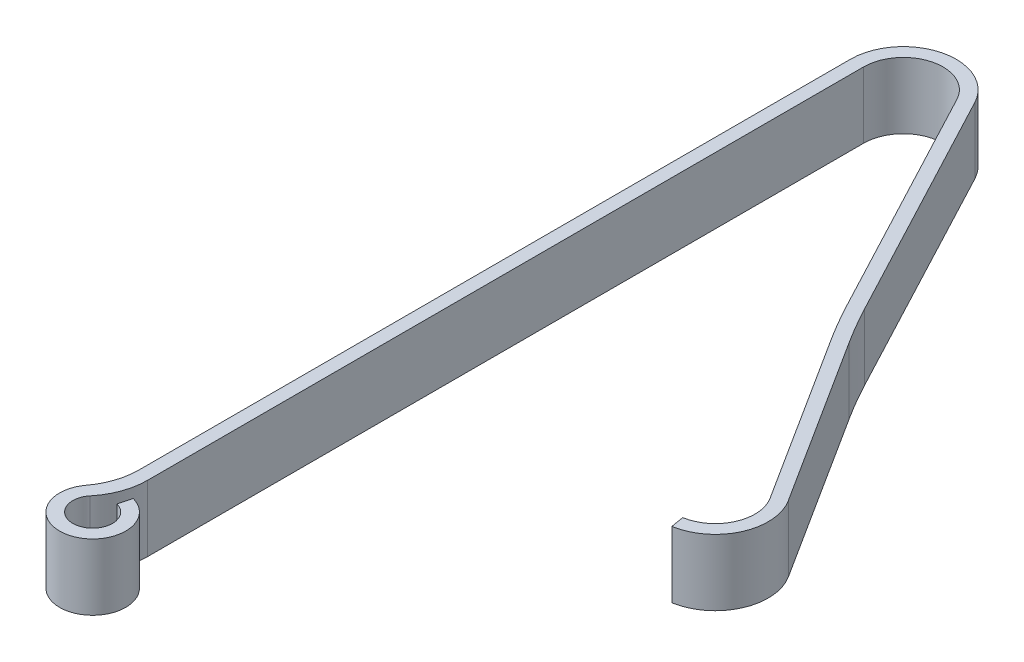
from build123d import *

# Parameters (mm, degrees)
BOSS_EXTRUDE1_DEPTH = 1.27
FILLET1_R           = 1.27


with BuildPart() as part:
    # Sketch1 → Boss-Extrude1 (new body)
    with BuildSketch(Plane(origin=(0, 0, 0), x_dir=(1, 0, 0), z_dir=(0, 1, 0))):
        with BuildLine():
            Line((0, 0), (0, 14.224))
            ThreePointArc((0, 14.224), (0.77136744, 15.210108975), (1.914194705, 14.698870794))
            Line((1.914194705, 14.698870794), (4.288548676, 10.207897267))
            ThreePointArc((4.288548676, 10.207897267), (4.486671136, 9.850723748), (4.698989351, 9.501801969))
            Line((4.698989351, 9.501801969), (6.744540566, 6.287487077))
            ThreePointArc((6.744540566, 6.287487077), (6.815438139, 5.328506429), (6.055012218, 4.739929527))
            Line((6.055012218, 4.739929527), (6.013106646, 4.990448833))
            ThreePointArc((6.013106646, 4.990448833), (6.583426086, 5.43188151), (6.530252906, 6.151116996))
            Line((6.530252906, 6.151116996), (4.484701691, 9.365431888))
            ThreePointArc((4.484701691, 9.365431888), (4.267075521, 9.723076711), (4.064, 10.089179569))
            Line((4.064, 10.089179569), (1.689646029, 14.580153096))
            ThreePointArc((1.689646029, 14.580153096), (0.83252558, 14.963581731), (0.254, 14.224))
            Line((0.254, 14.224), (0.254, -0.200987113))
            ThreePointArc((0.254, -0.200987113), (0.204269521, -0.959727605), (0.352610056, -0.213969373))
            Line((0.352610056, -0.213969373), (0.418350094, 0.031375786))
            ThreePointArc((0.418350094, 0.031375786), (0.301490909, -1.215208728), (0, 0))
        make_face()
    extrude(amount=BOSS_EXTRUDE1_DEPTH)

    # Fillet1
    fillet1_edges = [part.edges().sort_by_distance(p)[0] for p in [
        (0.254, 0.635, 0.200987113),
        (0, 0.635, 0),
    ]]
    fillet(fillet1_edges, radius=FILLET1_R)


solid = part.part
